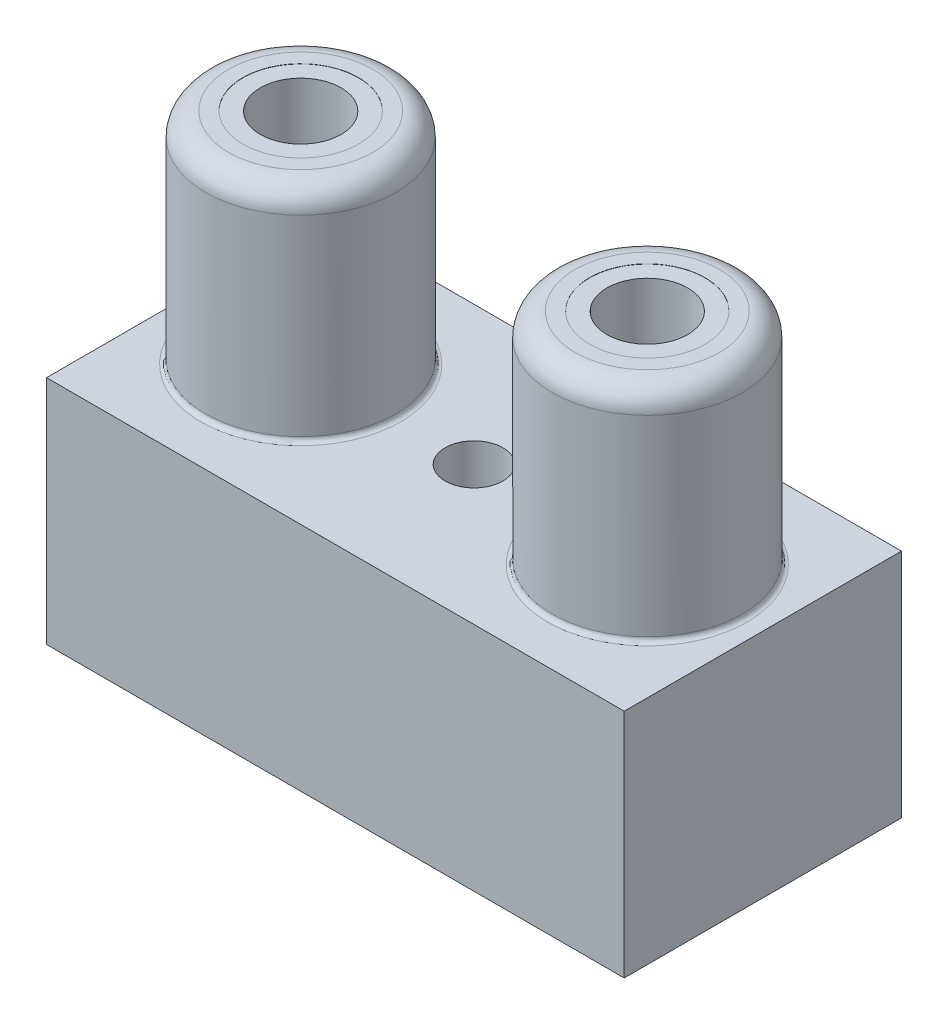
from build123d import *

# Parameters (mm, degrees)
ESQUISSE1_W             = 25
ESQUISSE1_H             = 12
BOSS_EXTRU_1_DEPTH      = 10
ESQUISSE2_R             = 4.12
BOSS_EXTRU_2_DEPTH      = 9.5
ESQUISSE3_R             = 2.5
ENL_V_MAT_EXTRU_1_DEPTH = 0.01
ESQUISSE4_R             = 1.75
ENL_V_MAT_EXTRU_2_DEPTH = 15
ESQUISSE5_R             = 1.25
ENL_V_MAT_EXTRU_3_DEPTH = 11
CONG_1_R                = 1
CONG_2_R                = 0.2


with BuildPart() as part:
    # Esquisse1 → Boss.-Extru.1 (new body)
    with BuildSketch(Plane(origin=(0, 0, 0), x_dir=(1, 0, 0), z_dir=(0, 1, 0))):
        with Locations((12.5, 6)):
            Rectangle(ESQUISSE1_W, ESQUISSE1_H)
    extrude(amount=BOSS_EXTRU_1_DEPTH)

    # Esquisse2 → Boss.-Extru.2 (add)
    with BuildSketch(Plane(origin=(0, 10, 0), x_dir=(1, 0, 0), z_dir=(0, 1, 0))):
        with Locations((5, 6)):
            Circle(ESQUISSE2_R)
        with Locations((20, 6)):
            Circle(ESQUISSE2_R)
    extrude(amount=BOSS_EXTRU_2_DEPTH)

    # Esquisse3 → Enlèv. mat.-Extru.1 (cut)
    with BuildSketch(Plane(origin=(0, 19.5, 0), x_dir=(1, 0, 0), z_dir=(0, 1, 0))):
        with Locations((5, 6)):
            Circle(ESQUISSE3_R)
        with Locations((20, 6)):
            Circle(ESQUISSE3_R)
    extrude(amount=-ENL_V_MAT_EXTRU_1_DEPTH, mode=Mode.SUBTRACT)

    # Esquisse4 → Enlèv. mat.-Extru.2 (cut)
    with BuildSketch(Plane(origin=(0, 19.49, 0), x_dir=(1, 0, 0), z_dir=(0, 1, 0))):
        with Locations((5, 6)):
            Circle(ESQUISSE4_R)
        with Locations((20, 6)):
            Circle(ESQUISSE4_R)
    extrude(amount=-ENL_V_MAT_EXTRU_2_DEPTH, mode=Mode.SUBTRACT)

    # Esquisse5 → Enlèv. mat.-Extru.3 (cut, through all)
    with BuildSketch(Plane(origin=(0, 10, 0), x_dir=(1, 0, 0), z_dir=(0, 1, 0))):
        with Locations((12.5, 6)):
            Circle(ESQUISSE5_R)
    extrude(amount=-ENL_V_MAT_EXTRU_3_DEPTH, mode=Mode.SUBTRACT)

    # Congé1
    cong_1_edges = [part.edges().sort_by_distance(p)[0] for p in [
        (0.88, 19.5, -6),
        (15.88, 19.5, -6),
    ]]
    fillet(cong_1_edges, radius=CONG_1_R)

    # Congé2
    cong_2_edges = [part.edges().sort_by_distance(p)[0] for p in [
        (0.88, 10, -6),
        (15.88, 10, -6),
    ]]
    fillet(cong_2_edges, radius=CONG_2_R)


solid = part.part
